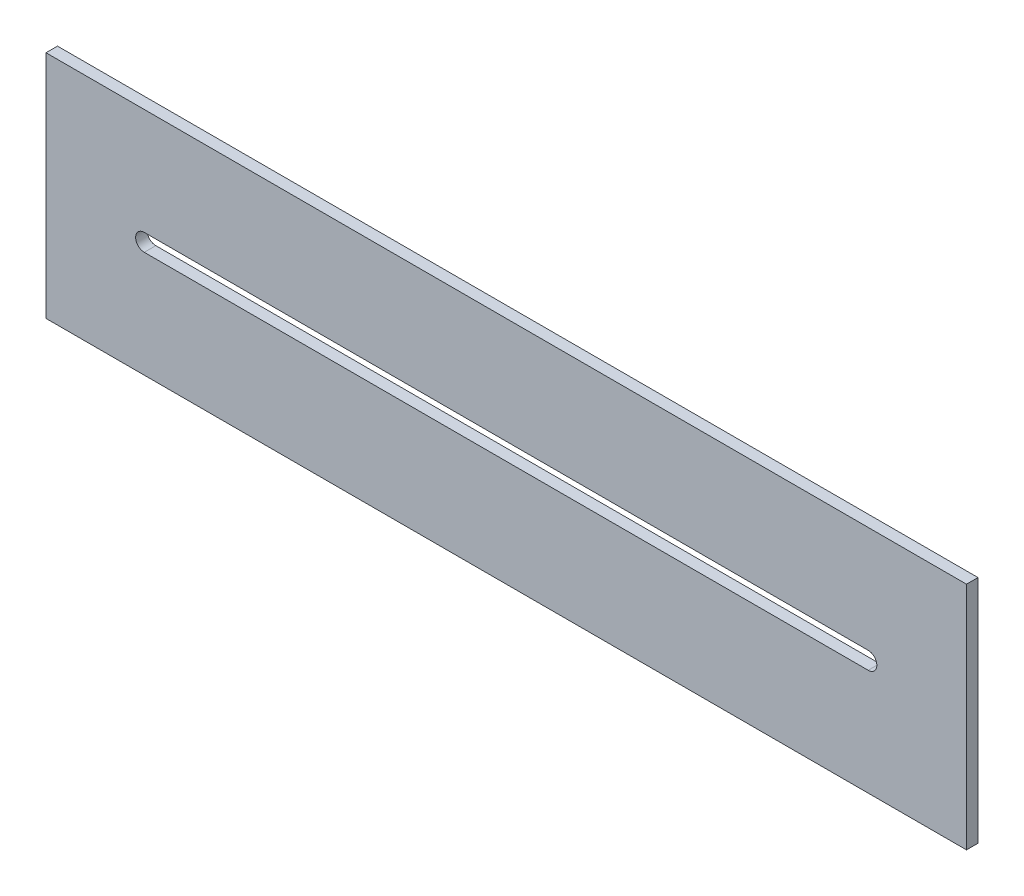
from build123d import *

# Parameters (mm, degrees)
SKETCH1_W           = 203.2
SKETCH1_H           = 50.8
BOSS_EXTRUDE1_DEPTH = 2.54


with BuildPart() as part:
    # Sketch1 → Boss-Extrude1 (new body)
    with BuildSketch(Plane.XY.offset(111.506)):
        with Locations((27.742628903, 3.491347131)):
            Rectangle(SKETCH1_W, SKETCH1_H)
        with BuildLine():
            Line((-52.164996369, 5.396347131), (107.650254176, 5.396347131))
            ThreePointArc((107.650254176, 5.396347131), (109.555254176, 3.491347131), (107.650254176, 1.586347131))
            Line((107.650254176, 1.586347131), (-52.164996369, 1.586347131))
            ThreePointArc((-52.164996369, 1.586347131), (-54.069996369, 3.491347131), (-52.164996369, 5.396347131))
        make_face(mode=Mode.SUBTRACT)
    extrude(amount=-BOSS_EXTRUDE1_DEPTH)


solid = part.part
